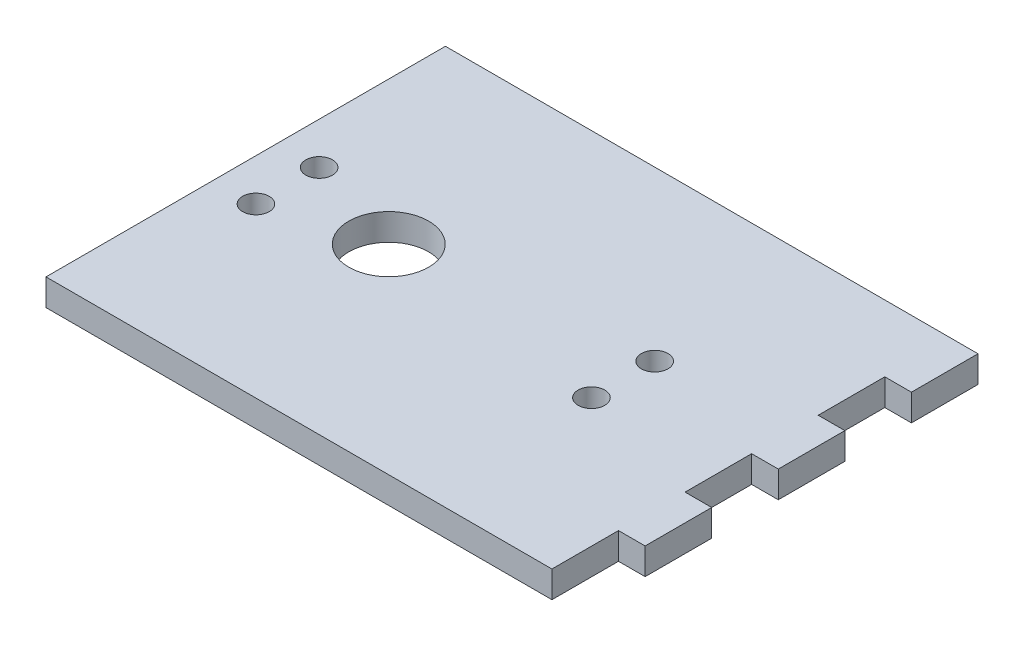
from build123d import *

# Parameters (mm, degrees)
SKETCH1_R           = 6
SKETCH1_R_2         = 2
BOSS_EXTRUDE1_DEPTH = 4


with BuildPart() as part:
    # Sketch1 → Boss-Extrude1 (new body)
    with BuildSketch(Plane(origin=(0, 0, 0), x_dir=(1, 0, 0), z_dir=(0, 1, 0))):
        Polygon((-9707.918733038, 15348.509362373), (-9631.918733038, 15348.509362373), (-9631.918733038, 15358.505402083), (-9627.918733038, 15358.505402083), (-9627.918733038, 15368.509362373), (-9631.918733038, 15368.509362373), (-9631.918733038, 15378.509362373), (-9627.918733038, 15378.509362373), (-9627.918733038, 15388.509362373), (-9631.918733038, 15388.509362373), (-9631.918733038, 15398.509362373), (-9627.918733038, 15398.509362373), (-9627.918733038, 15408.509362373), (-9707.918733038, 15408.509362373), align=None)
        with Locations((-9686.434317231, 15378.509362373)):
            Circle(SKETCH1_R, mode=Mode.SUBTRACT)
        with Locations((-9651.234317231, 15383.259362373)):
            Circle(SKETCH1_R_2, mode=Mode.SUBTRACT)
        with Locations((-9651.234317231, 15373.759362373)):
            Circle(SKETCH1_R_2, mode=Mode.SUBTRACT)
        with Locations((-9701.634317231, 15373.759362373)):
            Circle(SKETCH1_R_2, mode=Mode.SUBTRACT)
        with Locations((-9701.634317231, 15383.259362373)):
            Circle(SKETCH1_R_2, mode=Mode.SUBTRACT)
    extrude(amount=BOSS_EXTRUDE1_DEPTH)


solid = part.part
